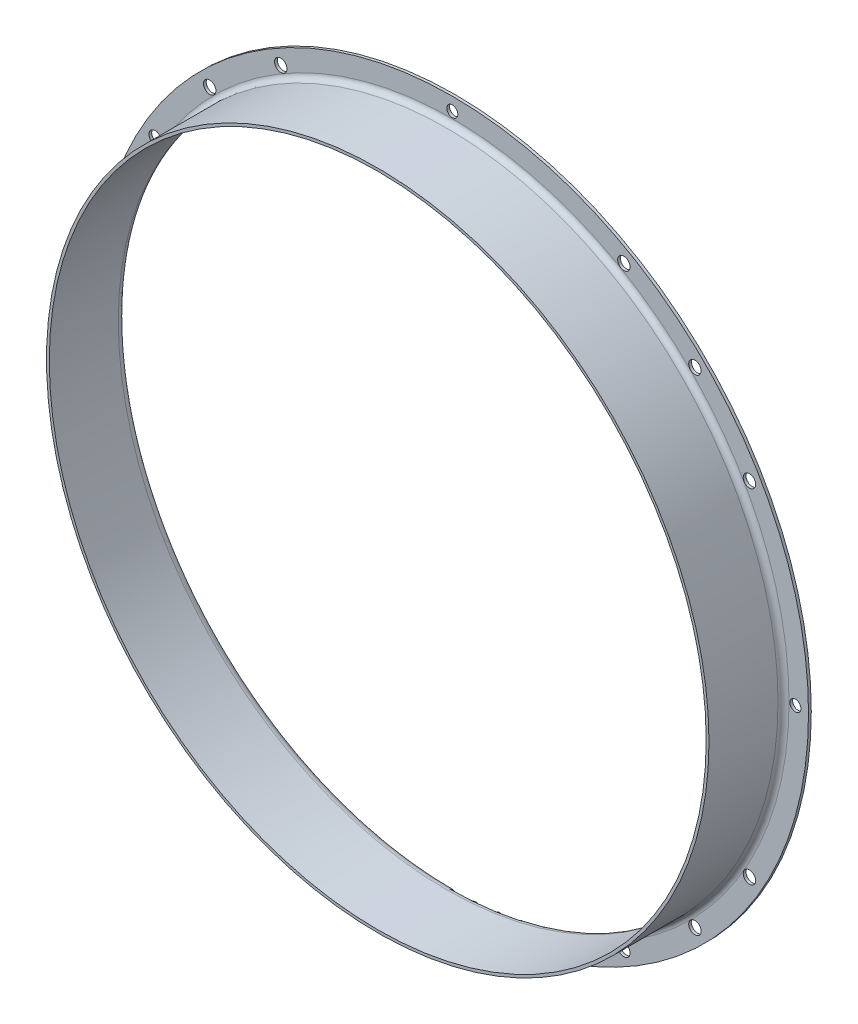
from build123d import *

# Parameters (mm, degrees)
F_4_5_4_5_DIAMETER_HOLE1_D = 4.5
CIRPATTERN1_COUNT          = 12
F_4_0_4_DIAMETER_HOLE1_D   = 4
CIRPATTERN2_COUNT          = 4
CIRPATTERN3_COUNT          = 4


with BuildPart() as part:
    # Sketch1 → Revolve1 (revolve)
    with BuildSketch(Plane(origin=(0, 0, 0), x_dir=(0, 0, -1), z_dir=(1, 0, 0)), mode=Mode.PRIVATE) as revolve1_sk:
        with BuildLine():
            Line((0, 129), (0, 121.95))
            ThreePointArc((0, 121.95), (-0.878679656, 119.828679656), (-3, 118.95))
            Line((-3, 118.95), (-28, 118.95))
            Line((-28, 118.95), (-28, 119.95))
            Line((-28, 119.95), (-3, 119.95))
            ThreePointArc((-3, 119.95), (-1.585786438, 120.535786438), (-1, 121.95))
            Line((-1, 121.95), (-1, 129))
            Line((-1, 129), (0, 129))
        make_face()
    revolve(revolve1_sk.sketch.rotate(Axis((0, 0, 36.289125048), (0, 0, -1)), 90), axis=Axis((0, 0, 36.289125048), (0, 0, -1)))  # turned: the seam where the file's is

    # Ø4.5 (4.5) Diameter Hole1 (through all)
    with Locations(Plane.XY.offset(1)):
        with Locations((62.125, 107.60365642)):
            f_4_5_4_5_diameter_hole1 = Hole(F_4_5_4_5_DIAMETER_HOLE1_D / 2)

    # CirPattern1: Ø4.5 (4.5) Diameter Hole1 ×12 about axis, 4 skipped
    cirpattern1_axis = Axis((0, 0, -80.9), (0, 0, 1))
    add([f_4_5_4_5_diameter_hole1.rotate(cirpattern1_axis, i * 360 / CIRPATTERN1_COUNT) for i in range(1, CIRPATTERN1_COUNT) if i not in (1, 4, 7, 10)], mode=Mode.SUBTRACT)

    # Ø4.0 (4) Diameter Hole1 (through all)
    with Locations(Plane.XY.offset(1)):
        with Locations((124.25, 0)):
            f_4_0_4_diameter_hole1 = Hole(F_4_0_4_DIAMETER_HOLE1_D / 2)

    # CirPattern2: Ø4.0 (4) Diameter Hole1 ×4 about axis
    cirpattern2_axis = Axis((0, 0, 0), (0, 0, 1))
    for i in range(1, CIRPATTERN2_COUNT):
        add(f_4_0_4_diameter_hole1.rotate(cirpattern2_axis, i * 360 / CIRPATTERN2_COUNT), mode=Mode.SUBTRACT)

    # Sketch7 → Ø4.5 (4.5) Diameter Hole2 (revolve, cut)
    with BuildSketch(Plane(origin=(87.858017562, 87.858017562, 1), x_dir=(0, -1, 0), z_dir=(1, 0, 0))):
        Polygon((0, 0), (0, 2.851936393), (2.25, 1.5), (2.25, 0), align=None)
    f_4_5_4_5_diameter_hole2 = revolve(axis=Axis((87.858017562, 87.858017562, 7.35), (0, 0, -1)), mode=Mode.SUBTRACT)

    # CirPattern3: Ø4.5 (4.5) Diameter Hole2 ×4 about axis
    cirpattern3_axis = Axis((0, 0, 0), (0, 0, 1))
    for i in range(1, CIRPATTERN3_COUNT):
        add(f_4_5_4_5_diameter_hole2.rotate(cirpattern3_axis, i * 360 / CIRPATTERN3_COUNT), mode=Mode.SUBTRACT)


solid = part.part
